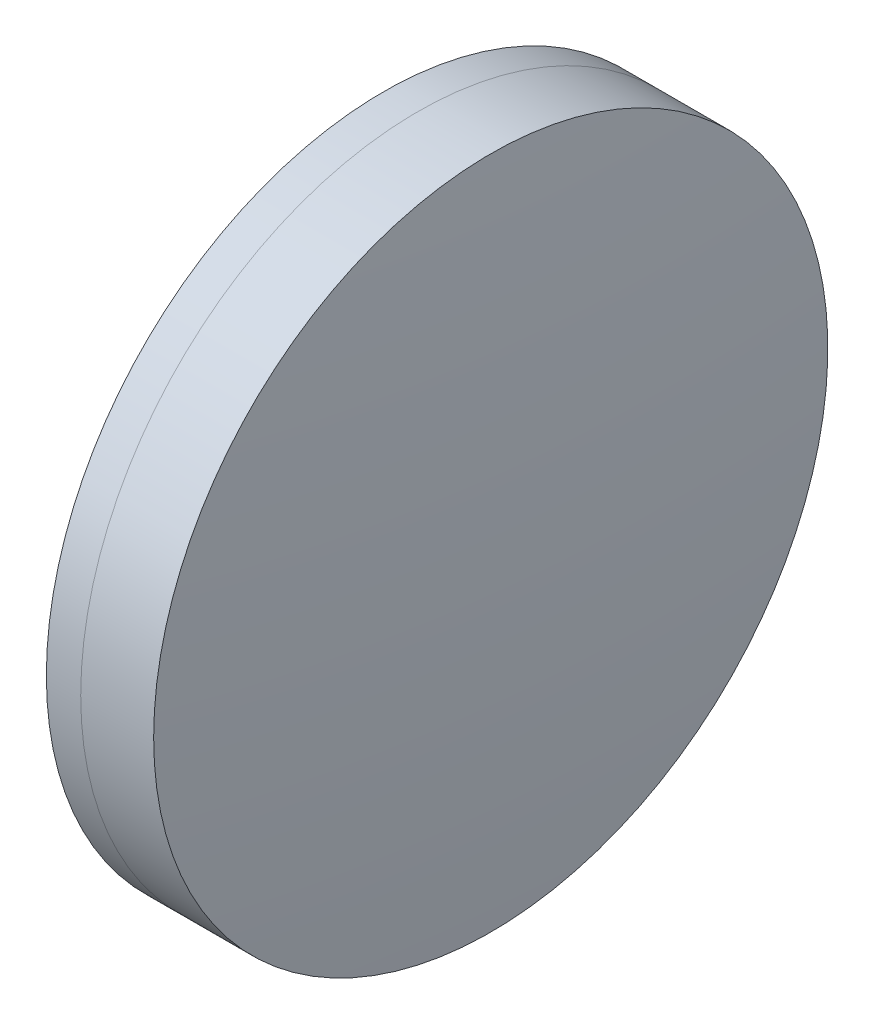
from build123d import *


with BuildPart() as part:
    # 草图1 one side → 旋转1 (revolve)
    with BuildSketch(Plane(origin=(0, 0, 0), x_dir=(1, 0, 0), z_dir=(0, 1, 0)), mode=Mode.PRIVATE) as revolve_1_sk:
        with BuildLine():
            ThreePointArc((280.878396474, 20), (279.376747876, 10.050068152), (278.874530354, 0))
            Line((278.874530354, 0), (285.614530354, 0))
            ThreePointArc((285.614530354, 0), (284.936998861, 10.090577298), (282.916568001, 20))
            Line((282.916568001, 20), (280.878396474, 20))
        make_face()
    revolve(revolve_1_sk.sketch.rotate(Axis((124.523309526, 0, 0), (1, 0, 0)), 180), axis=Axis((124.523309526, 0, 0), (1, 0, 0)))  # turned: the seam where the file's is


with BuildPart() as body_2:
    # 草图2 one side → 旋转3 (revolve)
    with BuildSketch(Plane(origin=(0, 0, 0), x_dir=(1, 0, 0), z_dir=(0, 1, 0)), mode=Mode.PRIVATE) as revolve_3_sk:
        with BuildLine():
            Line((287.244420164, 20), (282.916568001, 20))
            ThreePointArc((282.916568001, 20), (284.936998861, 10.090577298), (285.614530354, 0))
            Line((285.614530354, 0), (288.114530354, 0))
            ThreePointArc((288.114530354, 0), (287.896899973, 10.009459173), (287.244420164, 20))
        make_face()
    revolve(revolve_3_sk.sketch.rotate(Axis((-0.551919993, 0, 0), (1, 0, 0)), 180), axis=Axis((-0.551919993, 0, 0), (1, 0, 0)))  # turned: the seam where the file's is


solid = Compound([part.part, body_2.part])
